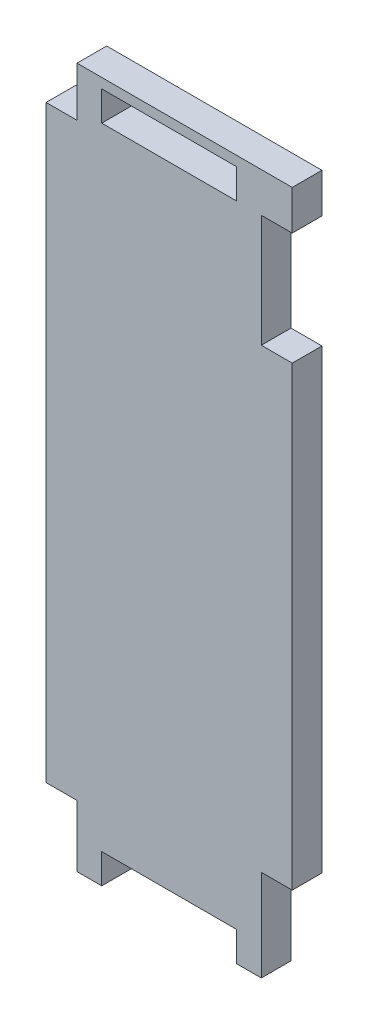
from build123d import *

# Parameters (mm, degrees)
SKETCH1_W           = 13.843
SKETCH1_H           = 3.048
SKETCH1_W_2         = 3.175
SKETCH1_H_2         = 0.381
BOSS_EXTRUDE1_DEPTH = 3.048


with BuildPart() as part:
    # Sketch1 → Boss-Extrude1 (new body)
    with BuildSketch(Plane.XY):
        Polygon((-3.175, 6.731), (0, 6.731), (0, 53.213), (-3.175, 53.213), (-3.175, 64.77), (0, 64.77), (0, 68.834), (-22.098, 68.834), (-22.098, 63.754), (-25.273, 63.754), (-25.273, 3.2766), (-22.098, 3.2766), (-22.098, -3.048), (-19.558, -3.048), (-19.558, 0), (-5.715, 0), (-5.715, -3.048), (-3.175, -3.048), (-3.175, 6.35), align=None)
        with Locations((-12.6365, 66.294)):
            Rectangle(SKETCH1_W, SKETCH1_H, mode=Mode.SUBTRACT)
        with Locations((-1.5875, 6.5405)):
            Rectangle(SKETCH1_W_2, SKETCH1_H_2)
    extrude(amount=BOSS_EXTRUDE1_DEPTH)


solid = part.part
